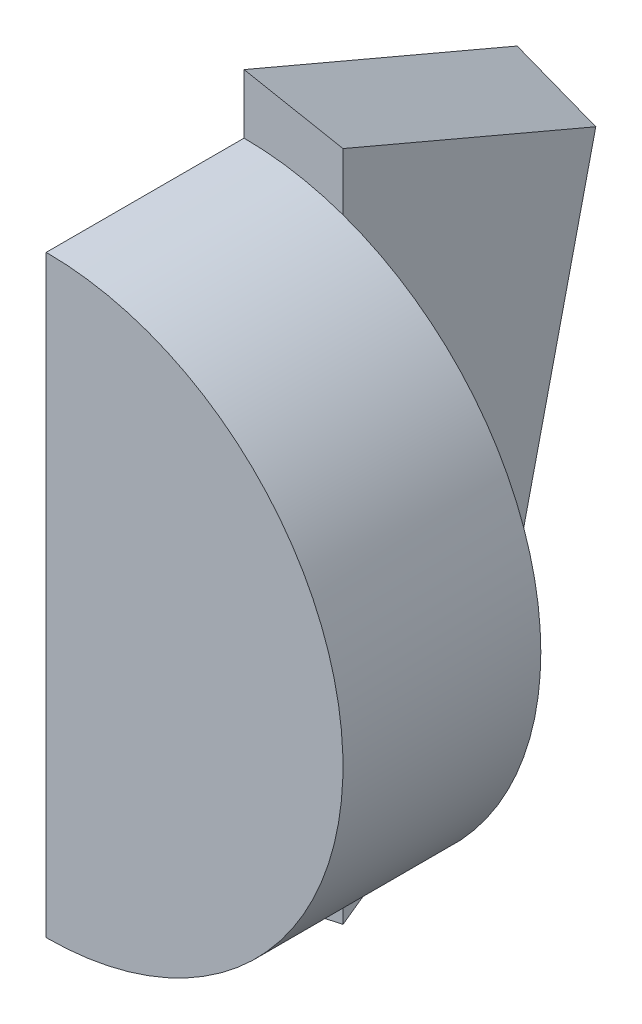
from build123d import *

# Parameters (mm, degrees)
BOSS_EXTRUDE1_DEPTH = 100
BOSS_EXTRUDE2_DEPTH = 50
DRAFT1_ANGLE        = 10


with BuildPart() as part:
    # Sketch1 → Boss-Extrude1 (new body)
    with BuildSketch(Plane.XY):
        with BuildLine():
            Line((0, 150), (0, -150))
            ThreePointArc((0, -150), (150, 0), (0, 150))
        make_face()
    extrude(amount=BOSS_EXTRUDE1_DEPTH)

    # Sketch2 → Boss-Extrude2 (add)
    with BuildSketch(Plane.ZY):
        Polygon((0, 180), (0, -180), (-81.642618236, -122.255018507), (-138.037816677, 121.301097394), align=None)
    extrude(amount=-BOSS_EXTRUDE2_DEPTH)

    # Draft1
    draft1_faces = [part.faces().sort_by_distance(p)[0] for p in [
        (25, -151.127509253, -40.821309118),
        (25, 150.650548697, -69.018908338),
        (25, -0.476960556, -109.840217456),
    ]]
    draft(draft1_faces, Plane(origin=(0, 0, 0), x_dir=(0, 0, 1), z_dir=(1, 0, 0)), DRAFT1_ANGLE)


solid = part.part
